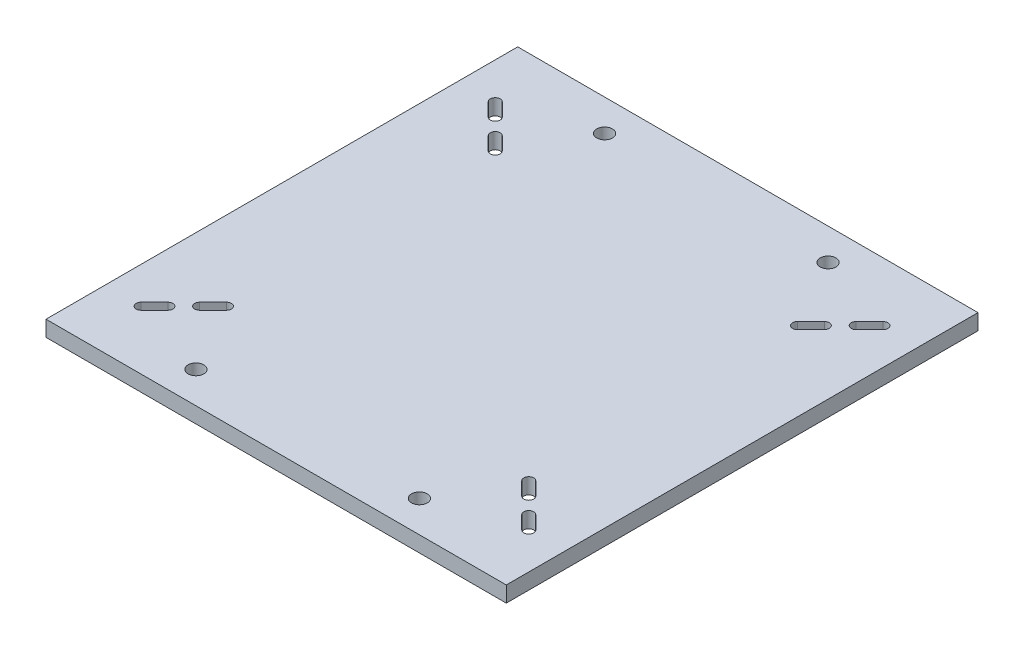
from build123d import *

# Parameters (mm, degrees)
SKETCH1_W              = 185.4
SKETCH1_H              = 190
BASE_PLATE_DEPTH       = 6.35
SLOTS_DEPTH            = 7.35
FEET_CONNECTION_HOLE_D = 6.35


with BuildPart() as part:
    # Sketch1 → base plate (new body)
    with BuildSketch(Plane(origin=(0, 0, 0), x_dir=(1, 0, 0), z_dir=(0, 1, 0))):
        with Locations((92.7, -95)):
            Rectangle(SKETCH1_W, SKETCH1_H)
    extrude(amount=-BASE_PLATE_DEPTH)

    # Sketch3 → slots (cut, through all)
    with BuildSketch(Plane(origin=(0, 0, 0), x_dir=(1, 0, 0), z_dir=(0, 1, 0))):
        with BuildLine():
            ThreePointArc((21.424612456, -27.64618524), (21.424612456, -30.474612456), (18.59618524, -30.474612456))
            Line((18.59618524, -30.474612456), (13.208031568, -25.086458783))
            ThreePointArc((13.208031568, -25.086458783), (13.208031568, -22.258031568), (16.036458783, -22.258031568))
            Line((16.036458783, -22.258031568), (21.424612456, -27.64618524))
        make_face()
        with BuildLine():
            Line((169.363541217, -22.258031568), (163.975387544, -27.64618524))
            ThreePointArc((163.975387544, -27.64618524), (163.975387544, -30.474612456), (166.80381476, -30.474612456))
            Line((166.80381476, -30.474612456), (172.191968432, -25.086458783))
            ThreePointArc((172.191968432, -25.086458783), (172.191968432, -22.258031568), (169.363541217, -22.258031568))
        make_face()
        with BuildLine():
            Line((154.995131423, -42.283295792), (160.383285096, -36.895142119))
            ThreePointArc((160.383285096, -36.895142119), (160.383285096, -34.066714904), (157.554857881, -34.066714904))
            Line((157.554857881, -34.066714904), (152.166704208, -39.454868577))
            ThreePointArc((152.166704208, -39.454868577), (152.166704208, -42.283295792), (154.995131423, -42.283295792))
        make_face()
        with BuildLine():
            ThreePointArc((160.383285096, -153.104857881), (160.383285096, -155.933285096), (157.554857881, -155.933285096))
            Line((157.554857881, -155.933285096), (152.166704208, -150.545131423))
            ThreePointArc((152.166704208, -150.545131423), (152.166704208, -147.716704208), (154.995131423, -147.716704208))
            Line((154.995131423, -147.716704208), (160.383285096, -153.104857881))
        make_face()
        with BuildLine():
            ThreePointArc((163.975387544, -162.35381476), (163.975387544, -159.525387544), (166.80381476, -159.525387544))
            Line((166.80381476, -159.525387544), (172.191968432, -164.913541217))
            ThreePointArc((172.191968432, -164.913541217), (172.191968432, -167.741968432), (169.363541217, -167.741968432))
            Line((169.363541217, -167.741968432), (163.975387544, -162.35381476))
        make_face()
        with BuildLine():
            Line((16.036458783, -167.741968432), (21.424612456, -162.35381476))
            ThreePointArc((21.424612456, -162.35381476), (21.424612456, -159.525387544), (18.59618524, -159.525387544))
            Line((18.59618524, -159.525387544), (13.208031568, -164.913541217))
            ThreePointArc((13.208031568, -164.913541217), (13.208031568, -167.741968432), (16.036458783, -167.741968432))
        make_face()
        with BuildLine():
            Line((30.404868577, -147.716704208), (25.016714904, -153.104857881))
            ThreePointArc((25.016714904, -153.104857881), (25.016714904, -155.933285096), (27.845142119, -155.933285096))
            Line((27.845142119, -155.933285096), (33.233295792, -150.545131423))
            ThreePointArc((33.233295792, -150.545131423), (33.233295792, -147.716704208), (30.404868577, -147.716704208))
        make_face()
        with BuildLine():
            Line((30.404868577, -42.283295792), (25.016714904, -36.895142119))
            ThreePointArc((25.016714904, -36.895142119), (25.016714904, -34.066714904), (27.845142119, -34.066714904))
            Line((27.845142119, -34.066714904), (33.233295792, -39.454868577))
            ThreePointArc((33.233295792, -39.454868577), (33.233295792, -42.283295792), (30.404868577, -42.283295792))
        make_face()
    extrude(amount=-SLOTS_DEPTH, mode=Mode.SUBTRACT)

    # Feet connection hole (through all)
    with Locations(Plane(origin=(0, 0, 0), x_dir=(1, 0, 0), z_dir=(0, 1, 0))):
        with Locations((47.7, -177.3), (137.7, -12.7), (47.7, -12.7), (137.7, -177.3)):
            Hole(FEET_CONNECTION_HOLE_D / 2)


solid = part.part
